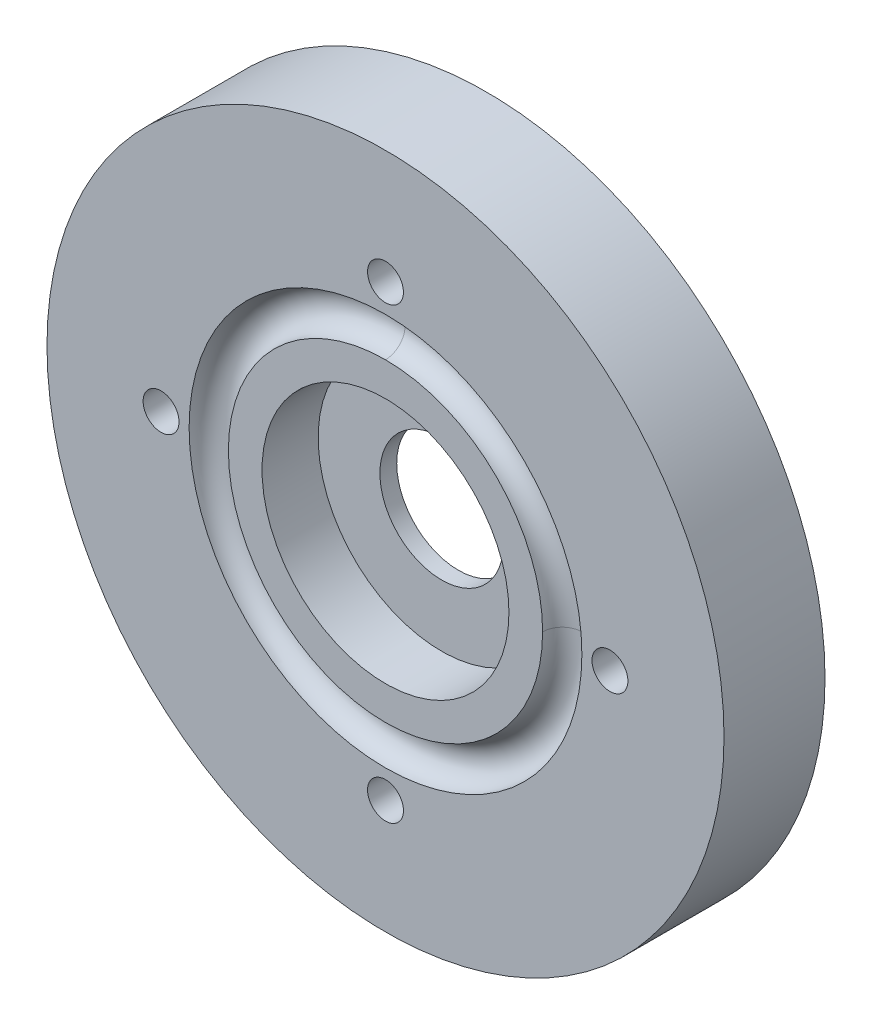
from build123d import *

# Parameters (mm, degrees)
SALIENTE_EXTRUIR1_DEPTH      = 4.5
SALIENTE_EXTRUIR1_DEPTH_BACK = 4.5
CROQUIS1_R                   = 30.165
CROQUIS1_R_2                 = 5.5
CROQUIS1_R_3                 = 1.6
SKETCH1_R                    = 9.5
CUT_EXTRUDE1_DEPTH           = 2.5
SKETCH2_R                    = 11
CUT_EXTRUDE2_DEPTH           = 5
CROQUIS3_R                   = 1.75


with BuildPart() as part:
    # Croquis1 → Saliente-Extruir1 (new, two sides: drawn at the far end of the back side and taken through both)
    with BuildSketch(Plane.XY.offset(-SALIENTE_EXTRUIR1_DEPTH_BACK)):
        Circle(CROQUIS1_R)
        Circle(CROQUIS1_R_2, mode=Mode.SUBTRACT)
        with Locations((20, 0)):
            Circle(CROQUIS1_R_3, mode=Mode.SUBTRACT)
        with Locations((-20, 0)):
            Circle(CROQUIS1_R_3, mode=Mode.SUBTRACT)
        with Locations((0, 20)):
            Circle(CROQUIS1_R_3, mode=Mode.SUBTRACT)
        with Locations((0, -20)):
            Circle(CROQUIS1_R_3, mode=Mode.SUBTRACT)
    extrude(amount=SALIENTE_EXTRUIR1_DEPTH + SALIENTE_EXTRUIR1_DEPTH_BACK)

    # Sketch1 → Cut-Extrude1 (cut)
    with BuildSketch(Plane(origin=(0, 0, -4.5), x_dir=(-1, 0, 0), z_dir=(0, 0, -1))):
        Circle(SKETCH1_R)
    extrude(amount=-CUT_EXTRUDE1_DEPTH, mode=Mode.SUBTRACT)

    # Sketch2 → Cut-Extrude2 (cut)
    with BuildSketch(Plane.XY.offset(4.5)):
        Circle(SKETCH2_R)
    extrude(amount=-CUT_EXTRUDE2_DEPTH, mode=Mode.SUBTRACT)

    # Cortar-Barrer1: sweep along a curve in space
    with BuildLine() as cortar_barrer1_path:
        ThreePointArc((11, 0, 4.5), (7.778174593, 7.778174593, 4.5), (0, 11, 4.5))
        ThreePointArc((0, 11, 4.5), (-7.778174593, 7.778174593, 4.5), (-11, 0, 4.5))
        ThreePointArc((-11, 0, 4.5), (-7.778174593, -7.778174593, 4.5), (0, -11, 4.5))
        ThreePointArc((0, -11, 4.5), (7.778174593, -7.778174593, 4.5), (11, 0, 4.5))
    # Croquis3 → Cortar-Barrer1 (sweep, cut)
    with BuildSketch(Plane(origin=(0, 0, 0), x_dir=(0, 0, -1), z_dir=(1, 0, 0))):
        with Locations((-4.5, 15.75)):
            Circle(CROQUIS3_R)
    sweep(path=cortar_barrer1_path.line, mode=Mode.SUBTRACT)


solid = part.part
